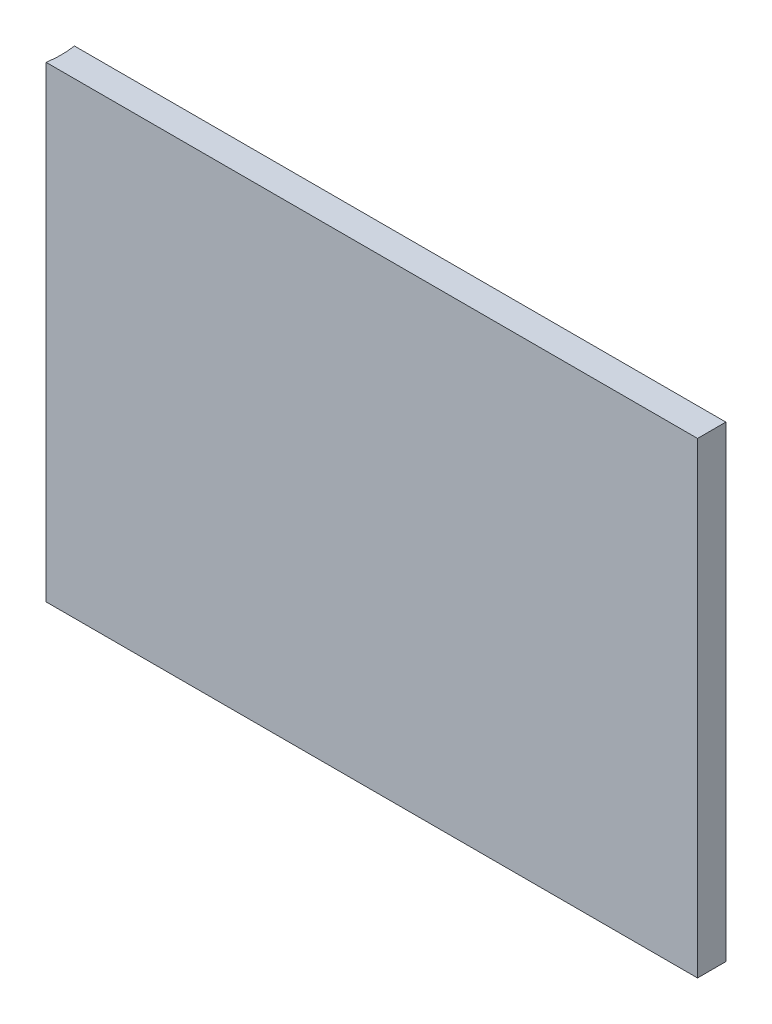
from build123d import *

# Parameters (mm, degrees)
SKETCH1_W           = 146.05
SKETCH1_H           = 104.775
BOSS_EXTRUDE1_DEPTH = 6.35
CUT_EXTRUDE1_DEPTH  = 105.775


with BuildPart() as part:
    # Sketch1 → Boss-Extrude1 (new body)
    with BuildSketch(Plane.XY):
        with Locations((-2.848492908, 4.610505319)):
            Rectangle(SKETCH1_W, SKETCH1_H)
    extrude(amount=BOSS_EXTRUDE1_DEPTH)

    # Sketch2 → Cut-Extrude1 (cut, through all)
    with BuildSketch(Plane(origin=(0, 56.998005319, 0), x_dir=(1, 0, 0), z_dir=(0, 1, 0))):
        with BuildLine():
            ThreePointArc((-75.873492908, -6.35), (-75.628562325, -3.175), (-75.873492908, 0))
            Line((-75.873492908, 0), (-75.873492908, -6.35))
        make_face()
    extrude(amount=-CUT_EXTRUDE1_DEPTH, mode=Mode.SUBTRACT)


solid = part.part
